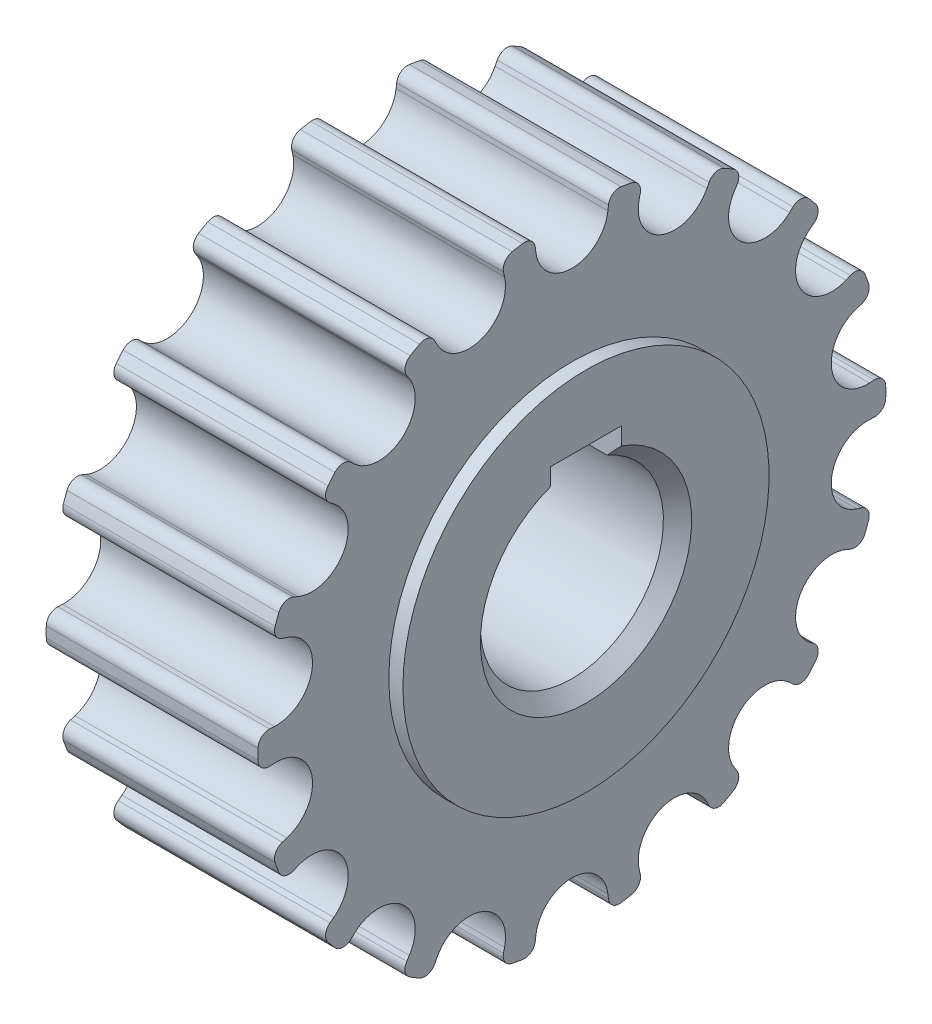
from build123d import *

# Parameters (mm, degrees)
CHAMFER_1_SIZE           = 1
SKETCH_4_W               = 5
SKETCH_4_H               = 2.299999952
CUT_EXTRUDE_1_DEPTH      = 36.280327549
CUT_EXTRUDE_2_REACH      = 37.28
PATTERN_CIRCULAR_3_COUNT = 18


with BuildPart() as part:
    # 草图1 → 旋转1 (revolve)
    with BuildSketch(Plane.XY):
        Polygon((0, 6.4838), (0, 22.234), (15, 22.234), (15, 12.9676), (16, 12.9676), (16, 6.4838), align=None)
    revolve(axis=Axis((0, 0, 0), (1, 0, 0)))

    # 倒角1
    chamfer_1_edges = [part.edges().sort_by_distance(p)[0] for p in [
        (16, -6.4838, 0),
        (0, -6.4838, 0),
    ]]
    chamfer(chamfer_1_edges, length=CHAMFER_1_SIZE)

    # 草图4 → 切除-拉伸1 (cut, through all)
    with BuildSketch(Plane.ZY):
        with Locations((0, 7.132446168)):
            Rectangle(SKETCH_4_W, SKETCH_4_H)
    extrude(amount=-CUT_EXTRUDE_1_DEPTH, mode=Mode.SUBTRACT)

    # 草图6 → 切除-拉伸2 (cut, up to next)
    with BuildSketch(Plane(origin=(0, 0, 0), x_dir=(0, 0, -1), z_dir=(1, 0, 0)), mode=Mode.PRIVATE) as cut_extrude_2_sk1:
        with BuildLine():
            Line((2.591680038, 21.283381802), (2.55084361, 20.950795787))
            ThreePointArc((2.55084361, 20.950795787), (0, 18.694), (-2.55084361, 20.950795787))
            Line((-2.55084361, 20.950795787), (-2.591680038, 21.283381802))
            ThreePointArc((-2.591680038, 21.283381802), (-2.896593224, 21.811367074), (-3.488238344, 21.95866456))
            ThreePointArc((-3.488238344, 21.95866456), (-3.872872102, 21.894100066), (-4.256314176, 21.822798758))
            Line((-4.256314176, 21.822798758), (-4.452962165, 23.4243681))
            ThreePointArc((-4.452962165, 23.4243681), (0, 23.843864891), (4.452962165, 23.4243681))
            Line((4.452962165, 23.4243681), (4.256314176, 21.822798758))
            ThreePointArc((4.256314176, 21.822798758), (3.872872102, 21.894100066), (3.488238344, 21.95866456))
            ThreePointArc((3.488238344, 21.95866456), (2.896593224, 21.811367074), (2.591680038, 21.283381802))
        make_face()
    cut_extrude_2_tool1 = extrude(cut_extrude_2_sk1.sketch, amount=CUT_EXTRUDE_2_REACH, mode=Mode.PRIVATE) & part.part
    cut_extrude_2 = cut_extrude_2_tool1.solids().sort_by_distance((0, 21.745564, 0))[0]
    add(cut_extrude_2, mode=Mode.SUBTRACT)

    # 阵列(圆周)3: 切除-拉伸2 ×18 about axis
    pattern_circular_3_axis = Axis((-1.4, 0, 0), (1, 0, 0))
    for i in range(1, PATTERN_CIRCULAR_3_COUNT):
        add(cut_extrude_2.rotate(pattern_circular_3_axis, i * 360 / PATTERN_CIRCULAR_3_COUNT), mode=Mode.SUBTRACT)


solid = part.part
